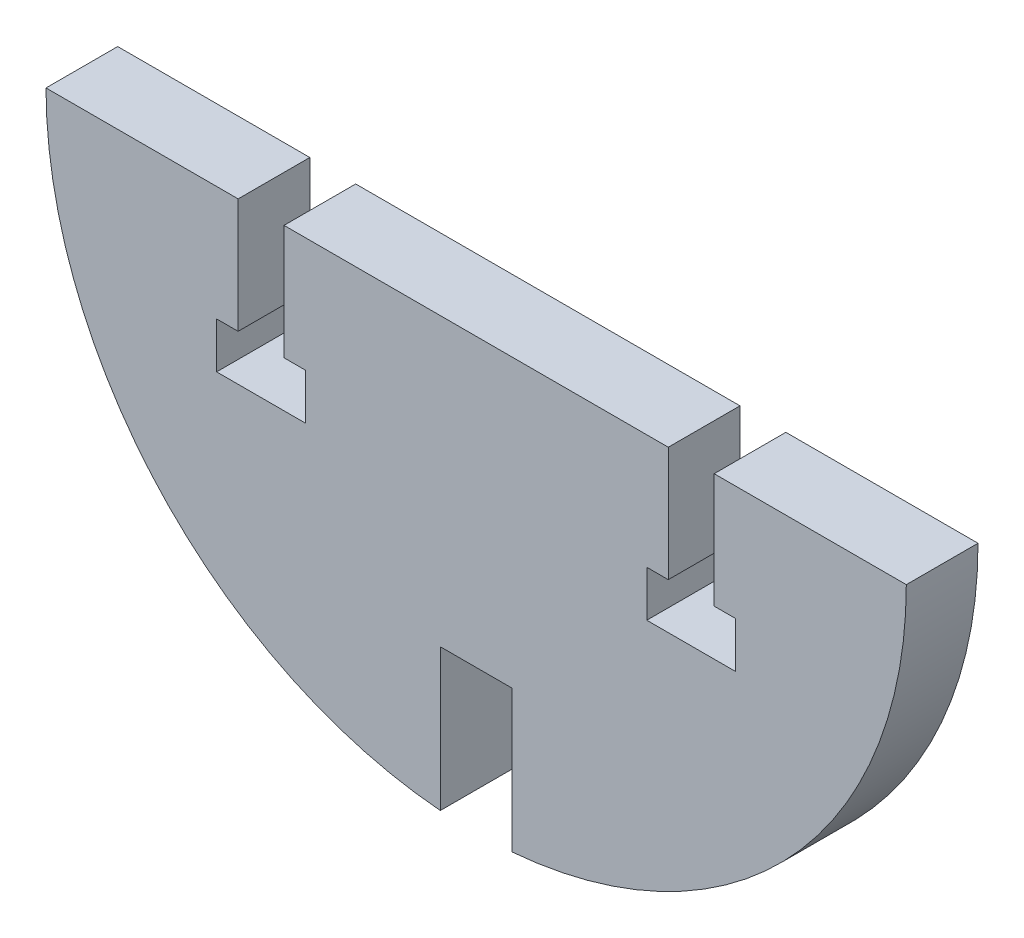
from build123d import *

# Parameters (mm, degrees)
BOSS_EXTRUDE1_DEPTH = 6.35


with BuildPart() as part:
    # Sketch1 → Boss-Extrude1 (new body)
    with BuildSketch(Plane.XY):
        with BuildLine():
            Line((3.175, 584.2), (20.193, 584.2))
            Line((20.193, 584.2), (20.193, 574.04))
            Line((20.193, 574.04), (18.288, 574.04))
            Line((18.288, 574.04), (18.288, 572.554033861))
            Line((18.288, 572.554033861), (18.288, 569.976))
            Line((18.288, 569.976), (26.162, 569.976))
            Line((26.162, 569.976), (26.162, 572.554033861))
            Line((26.162, 572.554033861), (26.162, 574.04))
            Line((26.162, 574.04), (24.257, 574.04))
            Line((24.257, 574.04), (24.257, 584.2))
            Line((24.257, 584.2), (41.275, 584.2))
            ThreePointArc((41.275, 584.2), (31.215840751, 558.406178065), (6.35, 546.232522141))
            Line((6.35, 546.232522141), (6.35, 558.8))
            Line((6.35, 558.8), (0, 558.8))
            Line((0, 558.8), (0, 546.232522141))
            ThreePointArc((0, 546.232522141), (-24.865840751, 558.406178065), (-34.925, 584.2))
            Line((-34.925, 584.2), (-17.907, 584.2))
            Line((-17.907, 584.2), (-17.907, 574.04))
            Line((-17.907, 574.04), (-19.812, 574.04))
            Line((-19.812, 574.04), (-19.812, 572.554033861))
            Line((-19.812, 572.554033861), (-19.812, 569.976))
            Line((-19.812, 569.976), (-11.938, 569.976))
            Line((-11.938, 569.976), (-11.938, 572.554033861))
            Line((-11.938, 572.554033861), (-11.938, 574.04))
            Line((-11.938, 574.04), (-13.843, 574.04))
            Line((-13.843, 574.04), (-13.843, 584.2))
            Line((-13.843, 584.2), (3.175, 584.2))
        make_face()
    extrude(amount=BOSS_EXTRUDE1_DEPTH)


solid = part.part
